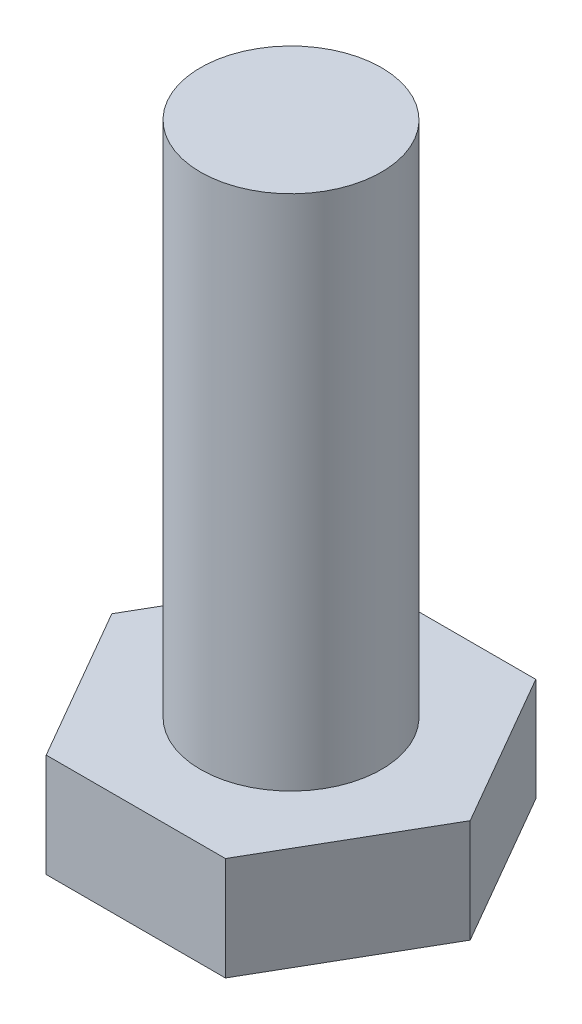
from build123d import *

# Parameters (mm, degrees)
BOSS_EXTRUDE1_DEPTH = 2
SKETCH2_R           = 1.75
BOSS_EXTRUDE2_DEPTH = 10


with BuildPart() as part:
    # Sketch1 → Boss-Extrude1 (new body)
    with BuildSketch(Plane(origin=(0, 0, 0), x_dir=(1, 0, 0), z_dir=(0, 1, 0))):
        Polygon((1.732050808, 3), (-1.732050808, 3), (-3.464101615, 0), (-1.732050808, -3), (1.732050808, -3), (3.464101615, 0), align=None)
    extrude(amount=BOSS_EXTRUDE1_DEPTH)

    # Sketch2 → Boss-Extrude2 (add)
    with BuildSketch(Plane(origin=(0, 2, 0), x_dir=(1, 0, 0), z_dir=(0, 1, 0))):
        Circle(SKETCH2_R)
    extrude(amount=BOSS_EXTRUDE2_DEPTH)


solid = part.part
